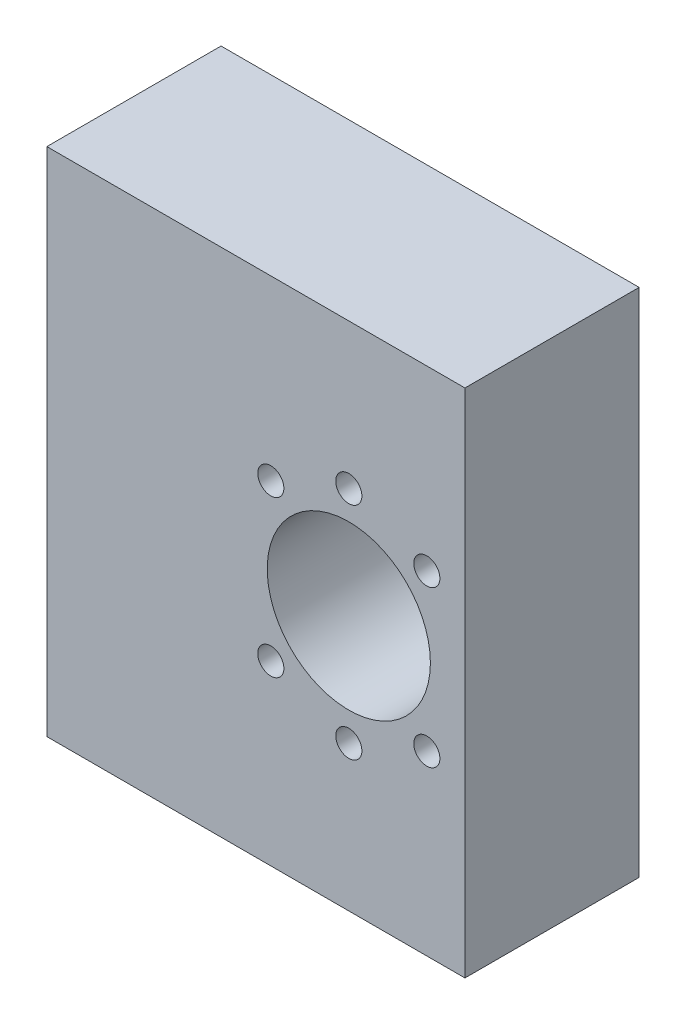
from build123d import *

# Parameters (mm, degrees)
EXTRUDE7_START     = 10
SKETCH1_W          = 72
SKETCH1_H          = 88
SKETCH1_R          = 14.05
SKETCH1_R_2        = 2.25
EXTRUDE7_DEPTH     = 30
SKETCH7_R          = 2.25
CUT_EXTRUDE5_DEPTH = 30


with BuildPart() as part:
    # Sketch1 → Extrude7 (new body)
    with BuildSketch(Plane.XY.offset(EXTRUDE7_START)):
        with Locations((-16, 0)):
            Rectangle(SKETCH1_W, SKETCH1_H)
        Circle(SKETCH1_R, mode=Mode.SUBTRACT)
        with Locations((-13.435028843, 13.435028843)):
            Circle(SKETCH1_R_2, mode=Mode.SUBTRACT)
        with Locations((0, 19)):
            Circle(SKETCH1_R_2, mode=Mode.SUBTRACT)
        with Locations((13.435028843, 13.435028843)):
            Circle(SKETCH1_R_2, mode=Mode.SUBTRACT)
        with Locations((13.435028843, -13.435028843)):
            Circle(SKETCH1_R_2, mode=Mode.SUBTRACT)
        with Locations((0, -19)):
            Circle(SKETCH1_R_2, mode=Mode.SUBTRACT)
        with Locations((-13.435028843, -13.435028843)):
            Circle(SKETCH1_R_2, mode=Mode.SUBTRACT)
    extrude(amount=EXTRUDE7_DEPTH)

    # Sketch7 → Cut-Extrude5 (cut)
    with BuildSketch(Plane.ZY.offset(52)):
        with Locations((17.5, 39)):
            Circle(SKETCH7_R)
        with Locations((17.5, 19)):
            Circle(SKETCH7_R)
        with Locations((17.5, -39)):
            Circle(SKETCH7_R)
        with Locations((17.5, -19)):
            Circle(SKETCH7_R)
        with Locations((17.5, 0)):
            Circle(SKETCH7_R)
        with Locations((32.5, -39)):
            Circle(SKETCH7_R)
        with Locations((32.5, -19)):
            Circle(SKETCH7_R)
        with Locations((32.5, 0)):
            Circle(SKETCH7_R)
        with Locations((32.5, 19)):
            Circle(SKETCH7_R)
        with Locations((32.5, 39)):
            Circle(SKETCH7_R)
    extrude(amount=-CUT_EXTRUDE5_DEPTH, mode=Mode.SUBTRACT)


solid = part.part
